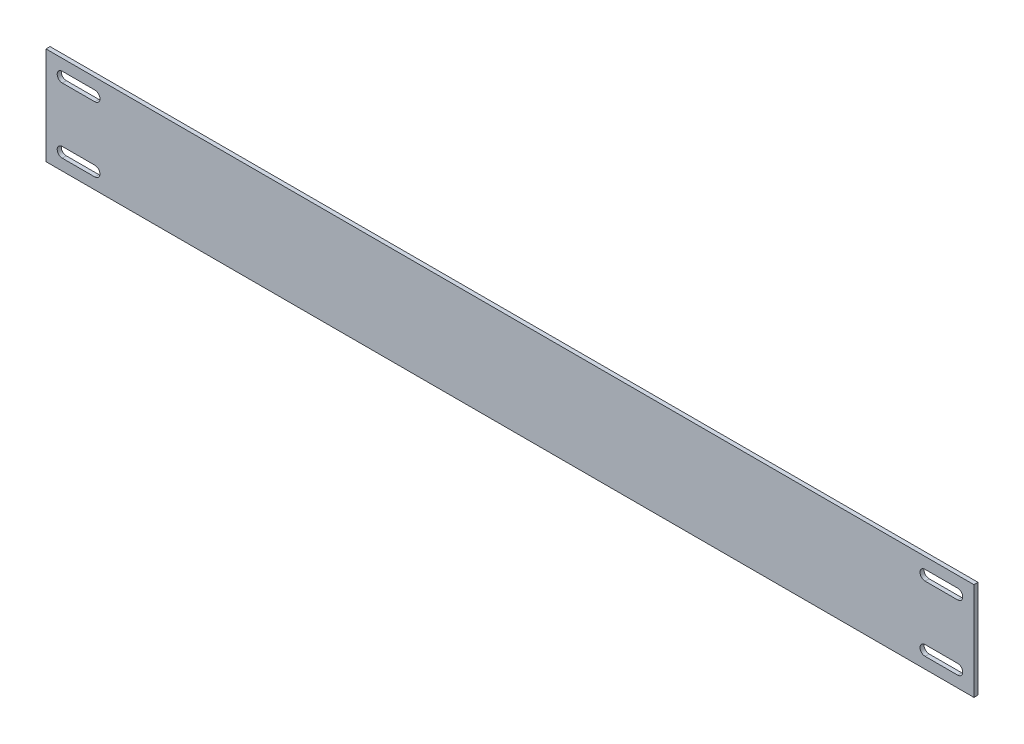
from build123d import *

# Parameters (mm, degrees)
BOSS_EXTRUDE1_DEPTH = 38.1
CUT_EXTRUDE2_DEPTH  = 2.5875


with BuildPart() as part:
    # Sketch1 → Boss-Extrude1 (new body)
    with BuildSketch(Plane(origin=(0, 0, 0), x_dir=(1, 0, 0), z_dir=(0, 1, 0))):
        Polygon((0, 0), (361.95, 0), (361.95, 1.5875), (336.55, 1.5875), (25.4, 1.5875), (0, 1.5875), align=None)
    extrude(amount=BOSS_EXTRUDE1_DEPTH)

    # Sketch2 → Cut-Extrude2 (cut, through all)
    with BuildSketch(Plane(origin=(0, 0, -1.5875), x_dir=(-1, 0, 0), z_dir=(0, 0, -1))):
        with BuildLine():
            Line((-19.05, 29.765625), (-6.35, 29.765625))
            ThreePointArc((-6.35, 29.765625), (-4.365625, 31.75), (-6.35, 33.734375))
            Line((-6.35, 33.734375), (-19.05, 33.734375))
            ThreePointArc((-19.05, 33.734375), (-21.034375, 31.75), (-19.05, 29.765625))
        make_face()
        with BuildLine():
            ThreePointArc((-6.35, 8.334375), (-4.365625, 6.35), (-6.35, 4.365625))
            Line((-6.35, 4.365625), (-19.05, 4.365625))
            ThreePointArc((-19.05, 4.365625), (-21.034375, 6.35), (-19.05, 8.334375))
            Line((-19.05, 8.334375), (-6.35, 8.334375))
        make_face()
        with BuildLine():
            Line((-342.9, 8.334375), (-355.6, 8.334375))
            ThreePointArc((-355.6, 8.334375), (-357.584375, 6.35), (-355.6, 4.365625))
            Line((-355.6, 4.365625), (-342.9, 4.365625))
            ThreePointArc((-342.9, 4.365625), (-340.915625, 6.35), (-342.9, 8.334375))
        make_face()
        with BuildLine():
            ThreePointArc((-355.6, 29.765625), (-357.584375, 31.75), (-355.6, 33.734375))
            Line((-355.6, 33.734375), (-342.9, 33.734375))
            ThreePointArc((-342.9, 33.734375), (-340.915625, 31.75), (-342.9, 29.765625))
            Line((-342.9, 29.765625), (-355.6, 29.765625))
        make_face()
    extrude(amount=-CUT_EXTRUDE2_DEPTH, mode=Mode.SUBTRACT)


solid = part.part
